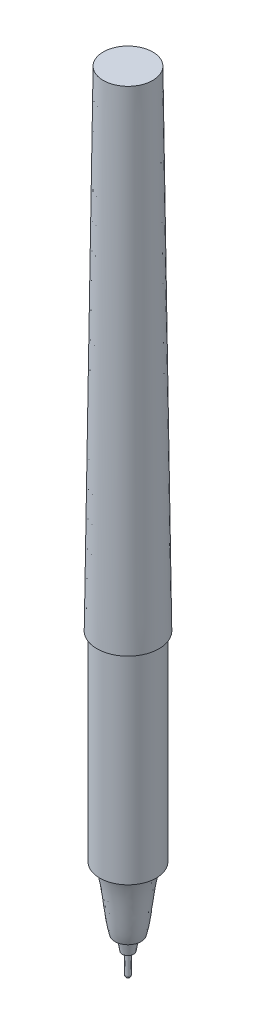
from build123d import *

# Parameters (mm, degrees)
SKETCH1_R           = 4.9911
SKETCH9_R           = 3.978249141
SKETCH11_R          = 4.5466
BOSS_EXTRUDE6_DEPTH = 32.1945


with BuildPart() as part:
    # Sketch1 → Loft2 section 0
    with BuildSketch(Plane(origin=(0, 0, 0), x_dir=(1, 0, 0), z_dir=(0, 1, 0))):
        Circle(SKETCH1_R)
    # Sketch9 → Loft2 section 1
    with BuildSketch(Plane(origin=(0, 78.74, 0), x_dir=(-1, 0, 0), z_dir=(0, 1, 0))):
        Circle(SKETCH9_R)
    loft()

    # Sketch11 → Boss-Extrude6 (add)
    with BuildSketch(Plane.XZ):
        Circle(SKETCH11_R)
    extrude(amount=BOSS_EXTRUDE6_DEPTH)

    # Sketch12 → Revolve1 (revolve)
    with BuildSketch(Plane.XY):
        with BuildLine():
            Line((0, -32.1945), (3.8608, -32.1945))
            add(Edge.make_bspline(
                [(3.8608, -32.1945), (2.870537627, -34.971866769), (2.812521689, -39.84117335), (2.10185, -42.2783)],
                knots=[0, 0, 0, 0, 1, 1, 1, 1], degree=3))
            Line((2.10185, -42.2783), (0, -42.2783))
            Line((0, -42.2783), (0, -32.1945))
        make_face()
    revolve(axis=Axis((0, -1000, 0), (0, 1, 0)))

    # Sketch13 → Revolve2 (revolve)
    with BuildSketch(Plane.XY):
        Polygon((0, -42.2783), (1.31445, -42.2783), (0.92075, -44.6278), (0, -44.6278), align=None)
    revolve(axis=Axis((0, -1000, 0), (0, 1, 0)))

    # Sketch14 → Revolve3 (revolve)
    with BuildSketch(Plane.XY):
        with BuildLine():
            Line((0, -44.6278), (0.40005, -44.6278))
            Line((0.40005, -44.6278), (0.40005, -47.904449612))
            ThreePointArc((0.40005, -47.904449612), (0.283254558, -48.189563905), (0, -48.3108))
            Line((0, -48.3108), (0, -44.6278))
        make_face()
    revolve(axis=Axis((0, -1000, 0), (0, 1, 0)))


solid = part.part
